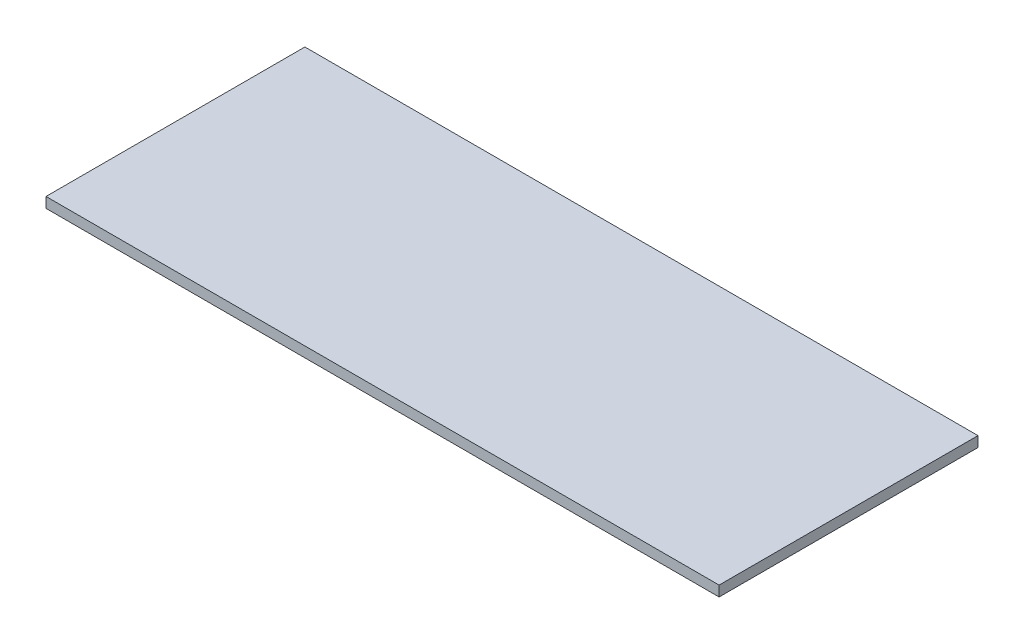
from build123d import *

# Parameters (mm, degrees)
SKETCH1_W           = 520
SKETCH1_H           = 200
BOSS_EXTRUDE1_DEPTH = 8


with BuildPart() as part:
    # Sketch1 → Boss-Extrude1 (new body)
    with BuildSketch(Plane(origin=(0, 0, 0), x_dir=(1, 0, 0), z_dir=(0, 1, 0))):
        Rectangle(SKETCH1_W, SKETCH1_H)
    extrude(amount=BOSS_EXTRUDE1_DEPTH)


solid = part.part
